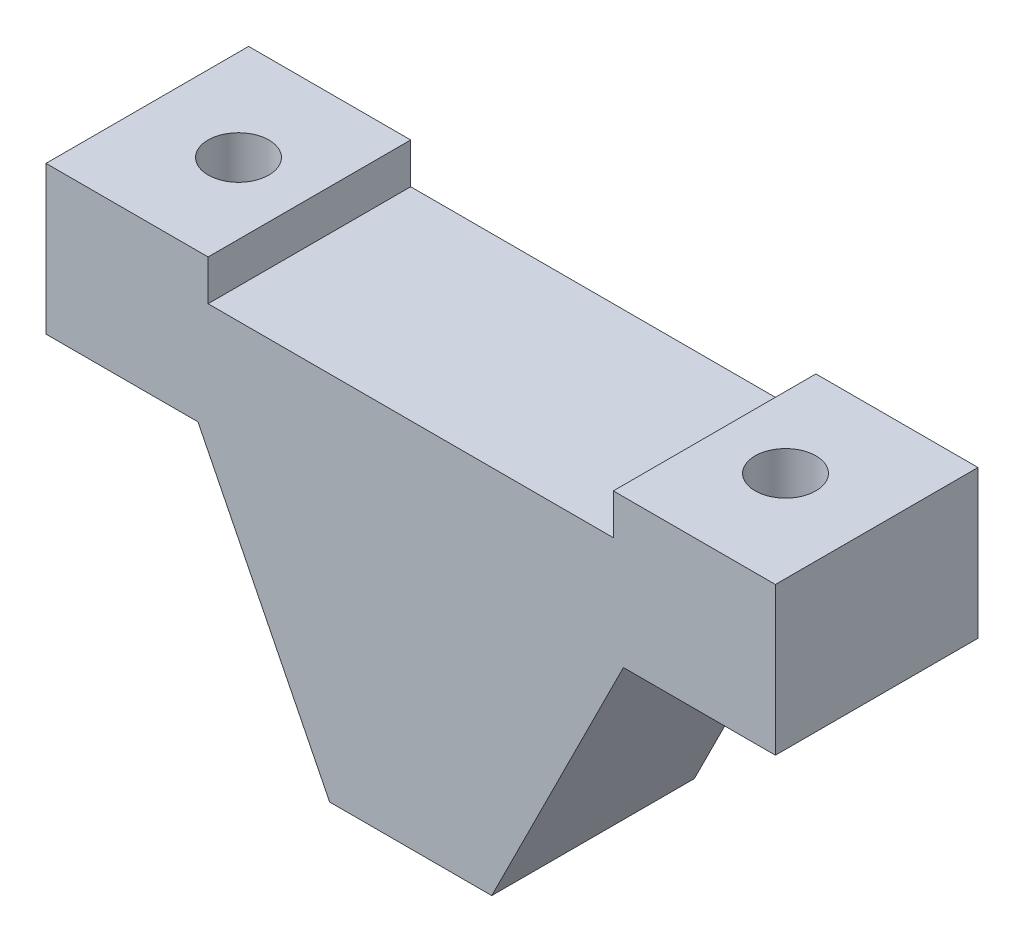
from build123d import *

# Parameters (mm, degrees)
BOSS_EXTRUDE1_DEPTH     = 10
SKETCH2_W               = 20
SKETCH2_H               = 2
CUT_EXTRUDE1_DEPTH      = 11
SKETCH3_R               = 1.5
CUT_EXTRUDE2_DEPTH      = 1
CUT_EXTRUDE2_DEPTH_BACK = 21.3


with BuildPart() as part:
    # Sketch1 → Boss-Extrude1 (new body)
    with BuildSketch(Plane.XY):
        Polygon((-4, 0), (4, 0), (10.5, 13), (18, 13), (18, 20.3), (-18, 20.3), (-18, 13), (-10.5, 13), align=None)
    extrude(amount=BOSS_EXTRUDE1_DEPTH)

    # Sketch2 → Cut-Extrude1 (cut, through all)
    with BuildSketch(Plane.XY.offset(10)):
        with Locations((0, 19.3)):
            Rectangle(SKETCH2_W, SKETCH2_H)
    extrude(amount=-CUT_EXTRUDE1_DEPTH, mode=Mode.SUBTRACT)

    # Sketch3 → Cut-Extrude2 (cut, two sides)
    with BuildSketch(Plane(origin=(0, 20.3, 0), x_dir=(1, 0, 0), z_dir=(0, 1, 0))) as cut_extrude2_sk:
        with Locations((-13.5, -5)):
            Circle(SKETCH3_R)
        with Locations((13.5, -5)):
            Circle(SKETCH3_R)
    extrude(amount=CUT_EXTRUDE2_DEPTH, mode=Mode.SUBTRACT)
    extrude(cut_extrude2_sk.sketch, amount=-CUT_EXTRUDE2_DEPTH_BACK, mode=Mode.SUBTRACT)


solid = part.part
